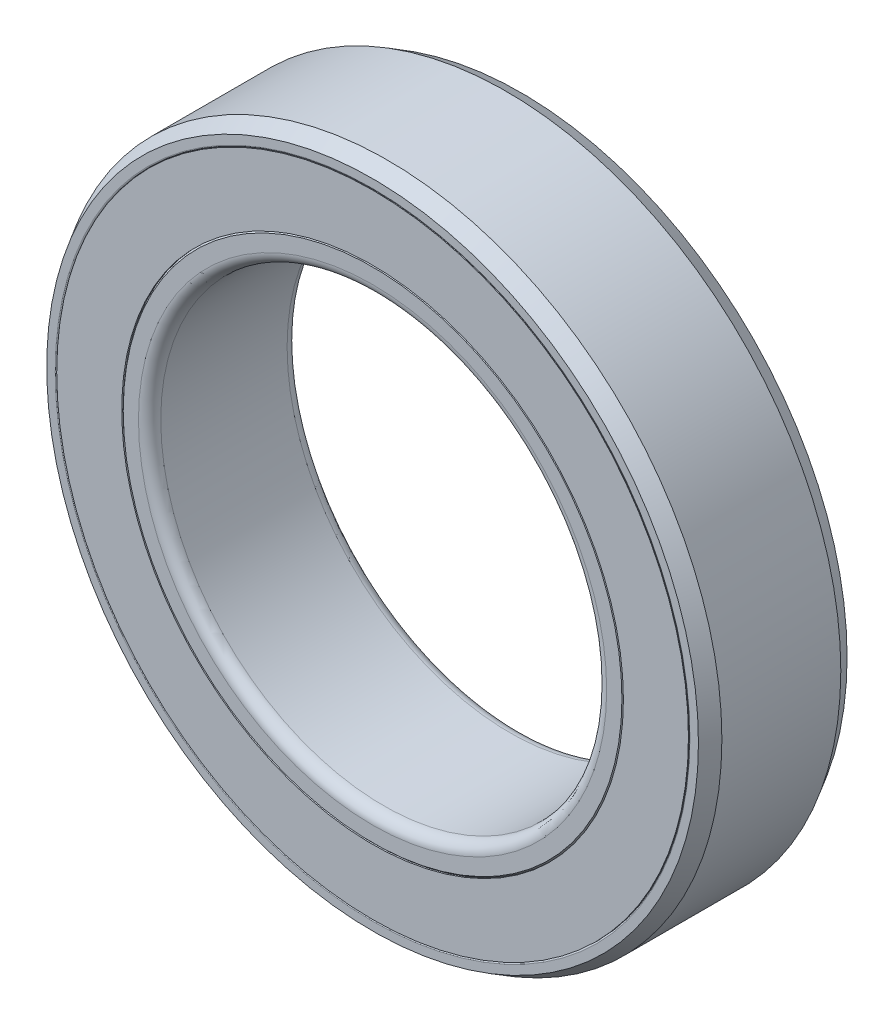
from build123d import *

# Parameters (mm, degrees)
SKETCH4_W         = 0.59375
SKETCH4_H         = 1.75
CIRPATTERN1_COUNT = 7


with BuildPart() as part:
    # Sketch3 → Revolve1 (revolve)
    with BuildSketch(Plane(origin=(0, 0, 0), x_dir=(0, 0, -1), z_dir=(1, 0, 0))):
        with BuildLine():
            Line((-1.6, -9), (1.6, -9))
            Line((1.6, -9), (2, -8.769059892))
            Line((2, -8.769059892), (2, -8.54))
            ThreePointArc((2, -8.54), (1.988284271, -8.511715729), (1.96, -8.5))
            Line((1.96, -8.5), (0.833333333, -8.5))
            ThreePointArc((0.833333333, -8.5), (0, -8.833333333), (-0.833333333, -8.5))
            Line((-0.833333333, -8.5), (-1.96, -8.5))
            ThreePointArc((-1.96, -8.5), (-1.988284271, -8.511715729), (-2, -8.54))
            Line((-2, -8.54), (-2, -8.769059892))
            Line((-2, -8.769059892), (-1.6, -9))
        make_face()
        with BuildLine():
            Line((-1.7, -6), (1.7, -6))
            ThreePointArc((1.7, -6), (1.912132034, -6.087867966), (2, -6.3))
            Line((2, -6.3), (2, -6.71))
            Line((2, -6.71), (1.96, -6.75))
            Line((1.96, -6.75), (0.833333333, -6.75))
            ThreePointArc((0.833333333, -6.75), (0, -6.416666667), (-0.833333333, -6.75))
            Line((-0.833333333, -6.75), (-1.96, -6.75))
            Line((-1.96, -6.75), (-2, -6.71))
            Line((-2, -6.71), (-2, -6.3))
            ThreePointArc((-2, -6.3), (-1.912132034, -6.087867966), (-1.7, -6))
        make_face()
    revolve(axis=Axis((0, 0, 2), (0, 0, -1)))


with BuildPart() as body_2:
    # Sketch4 → Revolve2 (revolve)
    with BuildSketch(Plane(origin=(0, 0, 0), x_dir=(0, 0, -1), z_dir=(1, 0, 0))):
        with Locations((-1.703125, -7.625)):
            Rectangle(SKETCH4_W, SKETCH4_H)
    revolve(axis=Axis((0, 0, 2), (0, 0, -1)))


with BuildPart() as body_3:
    # Sketch5 → Revolve3 (revolve)
    with BuildSketch(Plane(origin=(0, 0, 0), x_dir=(0, 0, -1), z_dir=(1, 0, 0))):
        with BuildLine():
            Line((0, -6.416666667), (0, -8.833333333))
            ThreePointArc((0, -8.833333333), (-1.208333333, -7.625), (0, -6.416666667))
        make_face()
    revolve(axis=Axis((0, 0, 0), (0, -1, 0)))


with BuildPart() as cirpattern1_1:
    # CirPattern1: pattern copy
    add(body_3.part.rotate(Axis((0, 0, 0), (0, 0, 1)), 1 * 360 / CIRPATTERN1_COUNT))


with BuildPart() as cirpattern1_2:
    # CirPattern1: pattern copy
    add(body_3.part.rotate(Axis((0, 0, 0), (0, 0, 1)), 2 * 360 / CIRPATTERN1_COUNT))


with BuildPart() as cirpattern1_3:
    # CirPattern1: pattern copy
    add(body_3.part.rotate(Axis((0, 0, 0), (0, 0, 1)), 3 * 360 / CIRPATTERN1_COUNT))


with BuildPart() as cirpattern1_4:
    # CirPattern1: pattern copy
    add(body_3.part.rotate(Axis((0, 0, 0), (0, 0, 1)), 4 * 360 / CIRPATTERN1_COUNT))


with BuildPart() as cirpattern1_5:
    # CirPattern1: pattern copy
    add(body_3.part.rotate(Axis((0, 0, 0), (0, 0, 1)), 5 * 360 / CIRPATTERN1_COUNT))


with BuildPart() as cirpattern1_6:
    # CirPattern1: pattern copy
    add(body_3.part.rotate(Axis((0, 0, 0), (0, 0, 1)), 6 * 360 / CIRPATTERN1_COUNT))


solid = Compound([part.part, body_2.part, body_3.part, cirpattern1_1.part, cirpattern1_2.part, cirpattern1_3.part, cirpattern1_4.part, cirpattern1_5.part, cirpattern1_6.part])
